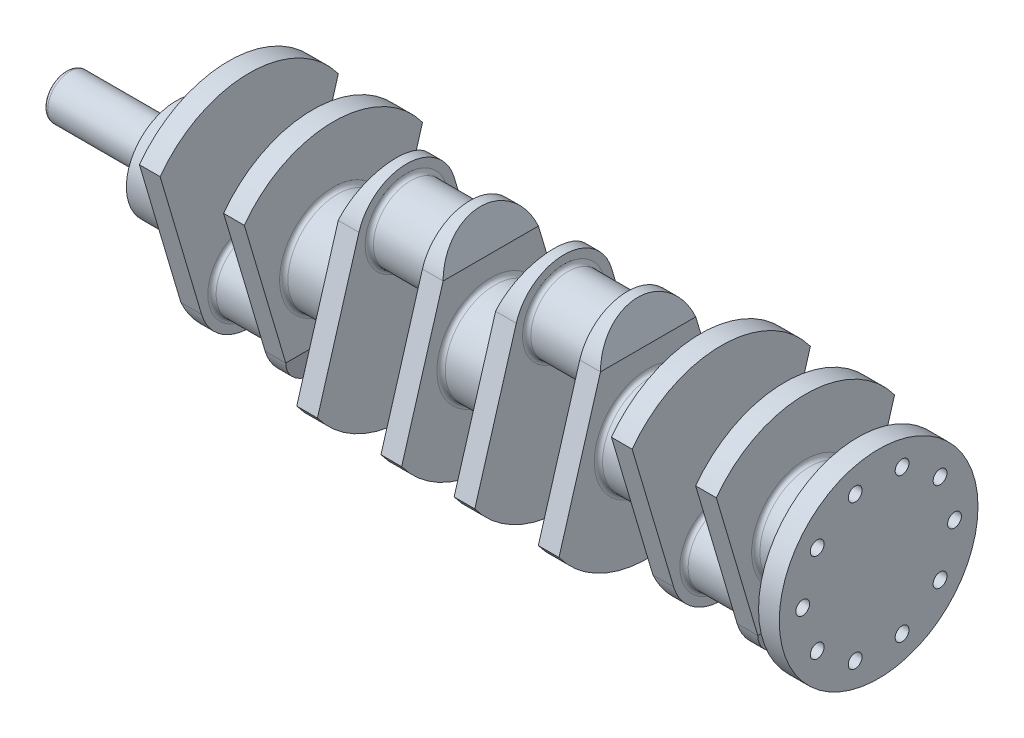
from build123d import *

# Parameters (mm, degrees)
SKETCH1_R                  = 36
BOSS_EXTRUDE1_DEPTH        = 19
SKETCH2_R                  = 27
BOSS_EXTRUDE2_DEPTH        = 15
SKETCH2_2_R                = 27
BOSS_EXTRUDE3_DEPTH        = 61
CUT_EXTRUDE1_DEPTH         = 65.569893475
CUT_EXTRUDE1_DEPTH_BACK    = 65.569893475
BODY_MOVE_COPY1_ANGLE      = 180
SKETCH4_R                  = 16
BOSS_EXTRUDE4_DEPTH        = 80
SKETCH5_R                  = 72
BOSS_EXTRUDE5_DEPTH        = 15
F_10_0MM_DOWEL_HOLE2_D     = 10
F_10_0MM_DOWEL_HOLE2_DEPTH = 15
CIRPATTERN3_COUNT          = 10
FILLET1_R                  = 3


with BuildPart() as part:
    # Sketch1 → Boss-Extrude1 (new body, symmetric)
    with BuildSketch(Plane(origin=(0, 0, 0), x_dir=(0, 0, -1), z_dir=(1, 0, 0))):
        Circle(SKETCH1_R)
    extrude(amount=BOSS_EXTRUDE1_DEPTH, both=True)

    # Sketch2 → Boss-Extrude2 (add)
    with BuildSketch(Plane(origin=(19, 0, 0), x_dir=(0, 0, -1), z_dir=(1, 0, 0))):
        with BuildLine():
            Line((-64.569893475, 47.23059238), (-34.517510455, -54.224552409))
            ThreePointArc((-34.517510455, -54.224552409), (0, -80), (34.517510455, -54.224552409))
            Line((34.517510455, -54.224552409), (64.569893475, 47.23059238))
            ThreePointArc((64.569893475, 47.23059238), (0, 80), (-64.569893475, 47.23059238))
        make_face()
        with Locations((0, -44)):
            Circle(SKETCH2_R, mode=Mode.SUBTRACT)
    extrude(amount=BOSS_EXTRUDE2_DEPTH)

    # Sketch2_2 → Boss-Extrude3 (add)
    with BuildSketch(Plane(origin=(19, 0, 0), x_dir=(0, 0, -1), z_dir=(1, 0, 0))):
        with Locations((0, -44)):
            Circle(SKETCH2_2_R)
    extrude(amount=BOSS_EXTRUDE3_DEPTH)

    # Sketch3 → Cut-Extrude1 (cut, two sides)
    with BuildSketch(Plane.XY) as cut_extrude1_sk:
        Polygon((19, -54.224552409), (26.5, -80), (19, -80), align=None)
    extrude(amount=CUT_EXTRUDE1_DEPTH, mode=Mode.SUBTRACT)
    extrude(cut_extrude1_sk.sketch, amount=-CUT_EXTRUDE1_DEPTH_BACK, mode=Mode.SUBTRACT)

    # Mirror4: part across plane


with BuildPart() as part_1:
    add(part.part)
    add(part.part.mirror(Plane(origin=(57, 0, 0), x_dir=(0, 0, 1), z_dir=(1, 0, 0))))


with BuildPart() as body_2:
    # Mirror5: mirrored copy
    add(part_1.part.mirror(Plane(origin=(114, 0, 0), x_dir=(0, 0, 1), z_dir=(1, 0, 0))))


with BuildPart() as body_2_1:
    # Body-Move_Copy1: moved
    add(body_2.part.rotate(Axis((0, 0, 0), (1, 0, 0)), BODY_MOVE_COPY1_ANGLE))


with BuildPart() as body_3:
    # Mirror6: mirrored copy
    add(part_1.part.mirror(Plane(origin=(228, 0, 0), x_dir=(0, 0, 1), z_dir=(1, 0, 0))))


with BuildPart() as body_4:
    # Mirror6 2: mirrored copy
    add(body_2_1.part.mirror(Plane(origin=(228, 0, 0), x_dir=(0, 0, 1), z_dir=(1, 0, 0))))


with BuildPart() as part_2:
    add(part_1.part)

    # Combine1: union body 2, body 4, body 3
    add(body_2_1.part)
    add(body_4.part)
    add(body_3.part)

    # Sketch4 → Boss-Extrude4 (add)
    with BuildSketch(Plane.ZY.offset(19)):
        Circle(SKETCH4_R)
    extrude(amount=BOSS_EXTRUDE4_DEPTH)

    # Sketch5 → Boss-Extrude5 (add)
    with BuildSketch(Plane(origin=(475, 0, 0), x_dir=(0, 0, -1), z_dir=(1, 0, 0))):
        Circle(SKETCH5_R)
    extrude(amount=BOSS_EXTRUDE5_DEPTH)

    # 10.0mm Dowel Hole2
    with Locations(Plane(origin=(490, 0, 0), x_dir=(0, 0, -1), z_dir=(1, 0, 0))):
        with Locations((55, 0)):
            f_10_0mm_dowel_hole2 = Hole(F_10_0MM_DOWEL_HOLE2_D / 2, depth=F_10_0MM_DOWEL_HOLE2_DEPTH)

    # CirPattern3: 10.0mm Dowel Hole2 ×10 about axis
    cirpattern3_axis = Axis((0, 0, 0), (1, 0, 0))
    for i in range(1, CIRPATTERN3_COUNT):
        add(f_10_0mm_dowel_hole2.rotate(cirpattern3_axis, i * 360 / CIRPATTERN3_COUNT), mode=Mode.SUBTRACT)

    # Fillet1
    fillet1_edges = [part_2.edges().sort_by_distance(p)[0] for p in [
        (34, -44, 27),
        (-19, 0, -16),
        (-99, 0, -16),
        (80, -44, 27),
        (95, 0, 36),
        (133, 0, 36),
        (209, 0, -36),
        (194, 44, -27),
        (148, 44, -27),
        (247, 0, -36),
        (262, 44, -27),
        (323, 0, -36),
        (308, 44, -27),
        (437, 0, 36),
        (475, 0, 36),
        (422, -44, 27),
        (376, -44, 27),
        (361, 0, -36),
    ]]
    fillet(fillet1_edges, radius=FILLET1_R)


solid = part_2.part
